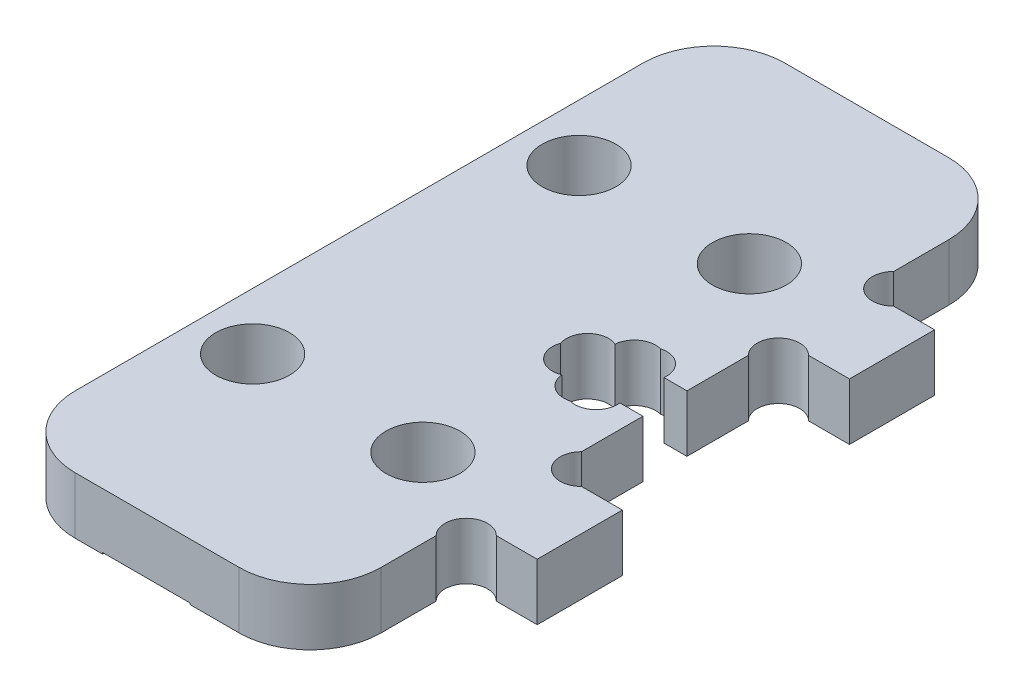
from build123d import *

# Parameters (mm, degrees)
SALIENTE_EXTRUIR1_DEPTH = 4
CROQUIS5_R              = 2.6
CORTAR_EXTRUIR3_DEPTH   = 5
CORTAR_EXTRUIR4_DEPTH   = 5
CROQUIS10_R             = 1.5
CORTAR_EXTRUIR5_DEPTH   = 5
CROQUIS4_W              = 6.15
CROQUIS4_H              = 53
CORTAR_EXTRUIR6_DEPTH   = 0.1


with BuildPart() as part:
    # Croquis1 → Saliente-Extruir1 (new body)
    with BuildSketch(Plane(origin=(0, 0, 0), x_dir=(1, 0, 0), z_dir=(0, 1, 0))):
        with BuildLine():
            Line((-5.775, -25), (5.775, -25))
            ThreePointArc((5.775, -25), (9.310533906, -23.535533906), (10.775, -20))
            Line((10.775, -20), (10.775, -14))
            Line((10.775, -14), (15.775, -14))
            Line((15.775, -14), (15.775, -8))
            Line((15.775, -8), (10.775, -8))
            Line((10.775, -8), (10.775, -1.55))
            Line((10.775, -1.55), (8.725, -1.55))
            Line((8.725, -1.55), (8.725, -2.8))
            Line((8.725, -2.8), (5.825, -2.8))
            Line((5.825, -2.8), (5.825, -1.55))
            Line((5.825, -1.55), (3.775, -1.55))
            Line((3.775, -1.55), (3.775, 1.55))
            Line((3.775, 1.55), (5.825, 1.55))
            Line((5.825, 1.55), (5.825, 2.8))
            Line((5.825, 2.8), (8.725, 2.8))
            Line((8.725, 2.8), (8.725, 1.55))
            Line((8.725, 1.55), (10.775, 1.55))
            Line((10.775, 1.55), (10.775, 8))
            Line((10.775, 8), (15.775, 8))
            Line((15.775, 8), (15.775, 14))
            Line((15.775, 14), (10.775, 14))
            Line((10.775, 14), (10.775, 20))
            ThreePointArc((10.775, 20), (9.310533906, 23.535533906), (5.775, 25))
            Line((5.775, 25), (-5.775, 25))
            ThreePointArc((-5.775, 25), (-9.310533906, 23.535533906), (-10.775, 20))
            Line((-10.775, 20), (-10.775, -20))
            ThreePointArc((-10.775, -20), (-9.310533906, -23.535533906), (-5.775, -25))
        make_face()
    extrude(amount=SALIENTE_EXTRUIR1_DEPTH)

    # Croquis5 → Cortar-Extruir3 (cut, through all)
    with BuildSketch(Plane(origin=(0, 4, 0), x_dir=(1, 0, 0), z_dir=(0, 1, 0))):
        with Locations((-6.775, 11.5)):
            Circle(CROQUIS5_R)
        with Locations((5.225, 11.5)):
            Circle(CROQUIS5_R)
        with Locations((5.225, -11.5)):
            Circle(CROQUIS5_R)
        with Locations((-6.775, -11.5)):
            Circle(CROQUIS5_R)
    extrude(amount=-CORTAR_EXTRUIR3_DEPTH, mode=Mode.SUBTRACT)

    # Croquis7 → Cortar-Extruir4 (cut, through all)
    with BuildSketch(Plane(origin=(0, 4, 0), x_dir=(1, 0, 0), z_dir=(0, 1, 0))):
        with BuildLine():
            Line((9.152341989, 1.55), (10.775, 1.55))
            Line((10.775, 1.55), (10.775, -1.55))
            Line((10.775, -1.55), (9.152341989, -1.55))
            ThreePointArc((9.152341989, -1.55), (8.650478098, -2.869619136), (7.275, -3.187930349))
            ThreePointArc((7.275, -3.187930349), (6.030747615, -2.971867524), (5.392475162, -1.882163243))
            ThreePointArc((5.392475162, -1.882163243), (3.80076038, -1.575149398), (3.41772275, 0))
            ThreePointArc((3.41772275, 0), (3.80076038, 1.575149398), (5.392475162, 1.882163243))
            ThreePointArc((5.392475162, 1.882163243), (6.030747615, 2.971867524), (7.275, 3.187930349))
            ThreePointArc((7.275, 3.187930349), (8.650478098, 2.869619136), (9.152341989, 1.55))
        make_face()
    extrude(amount=-CORTAR_EXTRUIR4_DEPTH, mode=Mode.SUBTRACT)

    # Croquis10 → Cortar-Extruir5 (cut, through all)
    with BuildSketch(Plane(origin=(0, 4, 0), x_dir=(1, 0, 0), z_dir=(0, 1, 0))):
        with Locations((11.835660172, 15.060660172)):
            Circle(CROQUIS10_R)
        with Locations((11.835660172, 6.939339828)):
            Circle(CROQUIS10_R)
        with Locations((11.835660172, -15.060660172)):
            Circle(CROQUIS10_R)
        with Locations((11.835660172, -6.939339828)):
            Circle(CROQUIS10_R)
    extrude(amount=-CORTAR_EXTRUIR5_DEPTH, mode=Mode.SUBTRACT)

    # Croquis4 → Cortar-Extruir6 (cut)
    with BuildSketch(Plane(origin=(0, 0, 0), x_dir=(1, 0, 0), z_dir=(0, 1, 0))):
        with Locations((-0.775, 0)):
            Rectangle(CROQUIS4_W, CROQUIS4_H)
    extrude(amount=CORTAR_EXTRUIR6_DEPTH, mode=Mode.SUBTRACT)


solid = part.part
